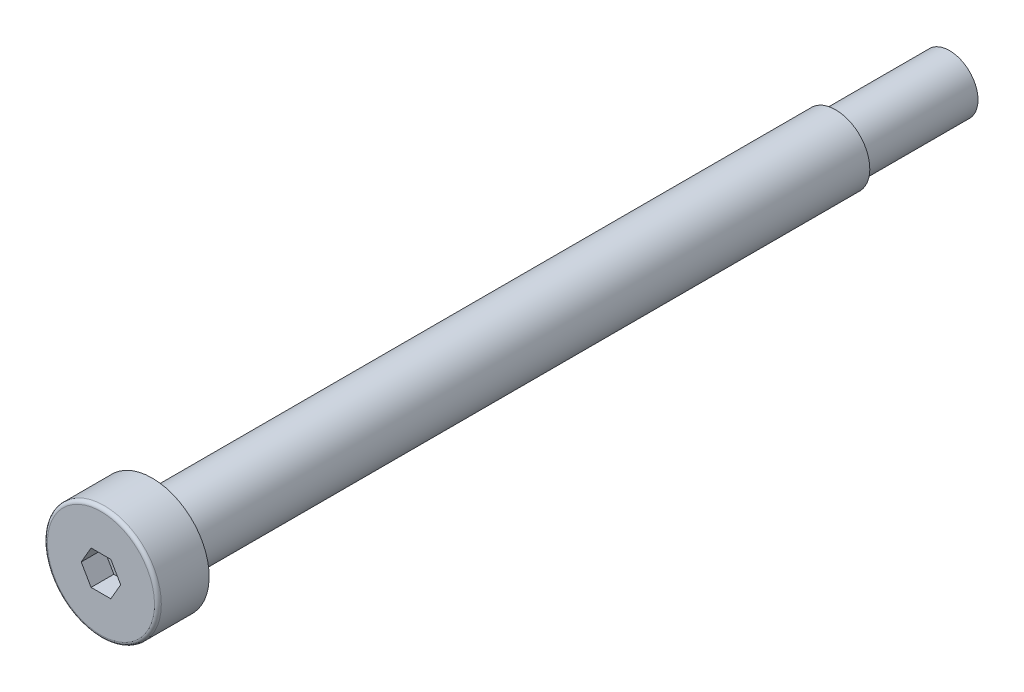
from build123d import *

# Parameters (mm, degrees)
CUT_EXTRUDE_1_DEPTH = 2
FILLET_1_R          = 0.3


with BuildPart() as part:
    # 草图1 → 旋转1 (revolve)
    with BuildSketch(Plane(origin=(0, 0, 0), x_dir=(0, 0, -1), z_dir=(1, 0, 0))):
        Polygon((0, 0), (0, 5), (4.5, 5), (4.5, 3), (64.5, 3), (64.5, 2.5), (74.5, 2.5), (74.5, 0), align=None)
    revolve(axis=Axis((0, 0, -74.5), (0, 0, 1)))

    # 草图2 → 切除-拉伸1 (cut)
    with BuildSketch(Plane.XY):
        Polygon((0.866025404, 1.5), (-0.866025404, 1.5), (-1.732050808, 0), (-0.866025404, -1.5), (0.866025404, -1.5), (1.732050808, 0), align=None)
    extrude(amount=-CUT_EXTRUDE_1_DEPTH, mode=Mode.SUBTRACT)

    # 圆角1
    fillet_1_edges = [part.edges().sort_by_distance(p)[0] for p in [
        (0, -5, 0),
    ]]
    fillet(fillet_1_edges, radius=FILLET_1_R)


solid = part.part
